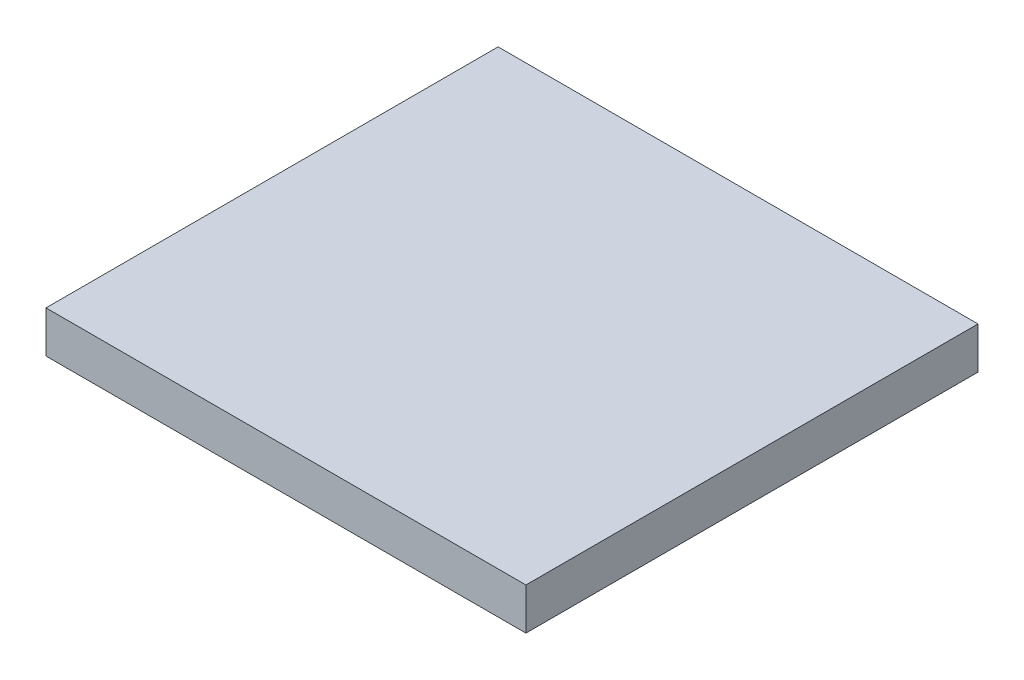
from build123d import *

# Parameters (mm, degrees)
SKETCH1_W           = 34.5
SKETCH1_H           = 32.5
BOSS_EXTRUDE1_DEPTH = 3


with BuildPart() as part:
    # Sketch1 → Boss-Extrude1 (new body)
    with BuildSketch(Plane(origin=(0, 0, 0), x_dir=(1, 0, 0), z_dir=(0, 1, 0))):
        with Locations((8.778638537, -19.670585773)):
            Rectangle(SKETCH1_W, SKETCH1_H)
    extrude(amount=BOSS_EXTRUDE1_DEPTH)


solid = part.part
